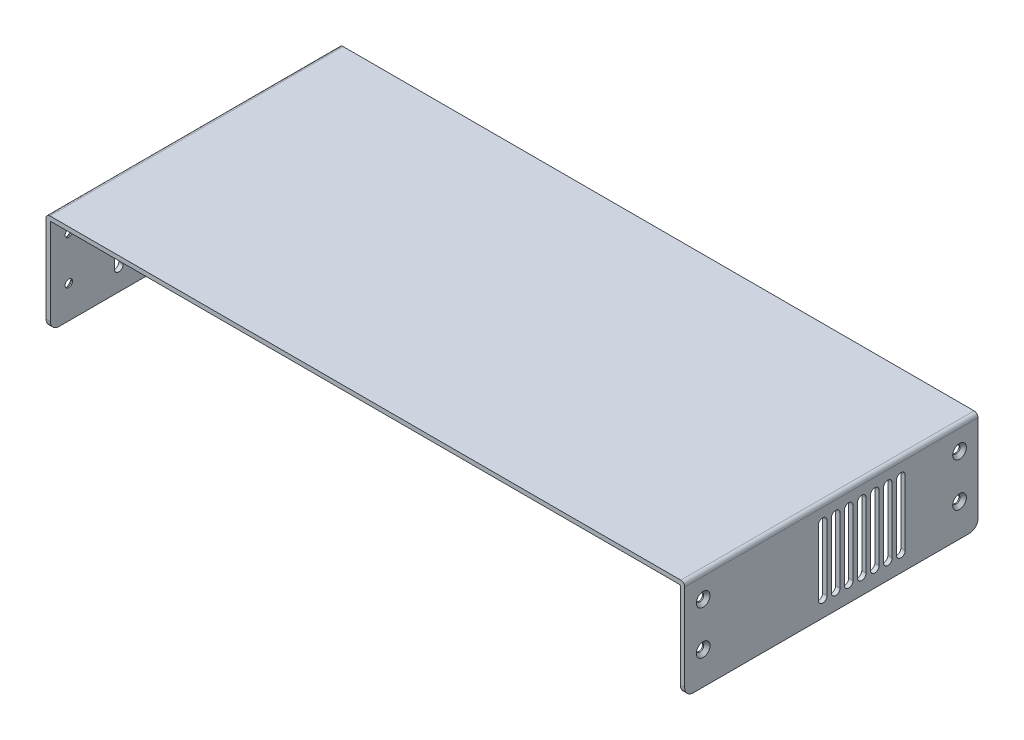
from build123d import *

# Parameters (mm, degrees)
BOSS_EXTRUDE1_DEPTH                             = 135
CSK_FOR_M3_FLAT_HEAD_MACHINE_SCREW1_D           = 3.4
CSK_FOR_M3_FLAT_HEAD_MACHINE_SCREW1_DEPTH       = 5
CSK_FOR_M3_FLAT_HEAD_MACHINE_SCREW1_CSINK_D     = 6.3
CSK_FOR_M3_FLAT_HEAD_MACHINE_SCREW1_CSINK_ANGLE = 90
CSK_FOR_M3_FLAT_HEAD_MACHINE_SCREW1_TIP         = 1.021463052
CSK_FOR_M3_FLAT_HEAD_MACHINE_SCREW2_D           = 3.4
CSK_FOR_M3_FLAT_HEAD_MACHINE_SCREW2_DEPTH       = 5
CSK_FOR_M3_FLAT_HEAD_MACHINE_SCREW2_CSINK_D     = 6.3
CSK_FOR_M3_FLAT_HEAD_MACHINE_SCREW2_CSINK_ANGLE = 90
CSK_FOR_M3_FLAT_HEAD_MACHINE_SCREW2_TIP         = 1.021463052
FILLET1_R                                       = 4
CUT_EXTRUDE1_DEPTH                              = 10
LPATTERN1_COUNT                                 = 13
LPATTERN1_PITCH                                 = 6
CUT_EXTRUDE2_DEPTH                              = 10
LPATTERN2_COUNT                                 = 7
LPATTERN2_PITCH                                 = 6


with BuildPart() as part:
    # Sketch1 → Boss-Extrude1 (new body)
    with BuildSketch(Plane.XY):
        with BuildLine():
            Line((0, 0), (-2, 0))
            Line((-2, 0), (-2, 44.2))
            ThreePointArc((-2, 44.2), (-1.472792206, 45.472792206), (-0.2, 46))
            Line((-0.2, 46), (290.2, 46))
            ThreePointArc((290.2, 46), (291.472792206, 45.472792206), (292, 44.2))
            Line((292, 44.2), (292, 0))
            Line((292, 0), (290, 0))
            Line((290, 0), (290, 43.5))
            ThreePointArc((290, 43.5), (289.853553391, 43.853553391), (289.5, 44))
            Line((289.5, 44), (0.5, 44))
            ThreePointArc((0.5, 44), (0.146446609, 43.853553391), (0, 43.5))
            Line((0, 43.5), (0, 0))
        make_face()
    extrude(amount=BOSS_EXTRUDE1_DEPTH)

    # CSK for M3 Flat Head Machine Screw1
    with Locations(Plane.ZY.offset(2)):
        with Locations((8.5, 35), (8.5, 15), (126.5, 35), (126.5, 15)):
            CounterSinkHole(CSK_FOR_M3_FLAT_HEAD_MACHINE_SCREW1_D / 2, CSK_FOR_M3_FLAT_HEAD_MACHINE_SCREW1_CSINK_D / 2, depth=CSK_FOR_M3_FLAT_HEAD_MACHINE_SCREW1_DEPTH, counter_sink_angle=CSK_FOR_M3_FLAT_HEAD_MACHINE_SCREW1_CSINK_ANGLE)
            with Locations((0, 0, -(CSK_FOR_M3_FLAT_HEAD_MACHINE_SCREW1_DEPTH + CSK_FOR_M3_FLAT_HEAD_MACHINE_SCREW1_TIP / 2))):  # 118° drill point
                Cone(0, CSK_FOR_M3_FLAT_HEAD_MACHINE_SCREW1_D / 2, CSK_FOR_M3_FLAT_HEAD_MACHINE_SCREW1_TIP, mode=Mode.SUBTRACT)

    # CSK for M3 Flat Head Machine Screw2
    with Locations(Plane(origin=(292, 0, 0), x_dir=(0, 0, -1), z_dir=(1, 0, 0))):
        with Locations((-126.5, 35), (-126.5, 15), (-8.5, 35), (-8.5, 15)):
            CounterSinkHole(CSK_FOR_M3_FLAT_HEAD_MACHINE_SCREW2_D / 2, CSK_FOR_M3_FLAT_HEAD_MACHINE_SCREW2_CSINK_D / 2, depth=CSK_FOR_M3_FLAT_HEAD_MACHINE_SCREW2_DEPTH, counter_sink_angle=CSK_FOR_M3_FLAT_HEAD_MACHINE_SCREW2_CSINK_ANGLE)
            with Locations((0, 0, -(CSK_FOR_M3_FLAT_HEAD_MACHINE_SCREW2_DEPTH + CSK_FOR_M3_FLAT_HEAD_MACHINE_SCREW2_TIP / 2))):  # 118° drill point
                Cone(0, CSK_FOR_M3_FLAT_HEAD_MACHINE_SCREW2_D / 2, CSK_FOR_M3_FLAT_HEAD_MACHINE_SCREW2_TIP, mode=Mode.SUBTRACT)

    # Fillet1
    fillet1_edges = [part.edges().sort_by_distance(p)[0] for p in [
        (-1, 0, 0),
        (291, 0, 0),
        (291, 0, 135),
        (-1, 0, 135),
    ]]
    fillet(fillet1_edges, radius=FILLET1_R)

    # Sketch6 → Cut-Extrude1 (cut)
    with BuildSketch(Plane(origin=(-2, 0, 0), x_dir=(0, 0, -1), z_dir=(1, 0, 0))):
        with BuildLine():
            Line((-101.5, 36), (-101.5, 10))
            ThreePointArc((-101.5, 10), (-103.5, 8), (-105.5, 10))
            Line((-105.5, 10), (-105.5, 36))
            ThreePointArc((-105.5, 36), (-103.5, 38), (-101.5, 36))
        make_face()
    cut_extrude1 = extrude(amount=CUT_EXTRUDE1_DEPTH, mode=Mode.SUBTRACT)

    # LPattern1: Cut-Extrude1 ×13
    with Locations(*[(0, 0, -i * LPATTERN1_PITCH) for i in range(1, LPATTERN1_COUNT)]):
        add(cut_extrude1, mode=Mode.SUBTRACT)

    # Sketch7 → Cut-Extrude2 (cut)
    with BuildSketch(Plane(origin=(292, 0, 0), x_dir=(0, 0, -1), z_dir=(1, 0, 0))):
        with BuildLine():
            Line((-33.5, 38), (-33.5, 8))
            ThreePointArc((-33.5, 8), (-35.5, 6), (-37.5, 8))
            Line((-37.5, 8), (-37.5, 38))
            ThreePointArc((-37.5, 38), (-35.5, 40), (-33.5, 38))
        make_face()
    cut_extrude2 = extrude(amount=-CUT_EXTRUDE2_DEPTH, mode=Mode.SUBTRACT)

    # LPattern2: Cut-Extrude2 ×7
    with Locations(*[(0, 0, i * LPATTERN2_PITCH) for i in range(1, LPATTERN2_COUNT)]):
        add(cut_extrude2, mode=Mode.SUBTRACT)


solid = part.part
